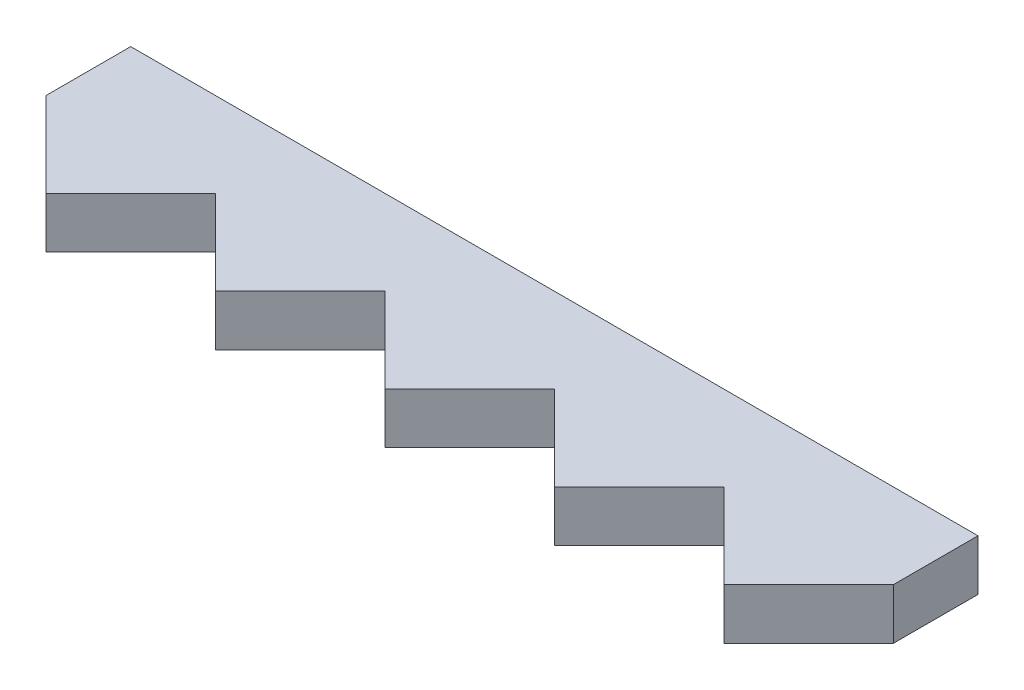
from build123d import *

# Parameters (mm, degrees)
BOSS_EXTRUDE1_DEPTH = 3


with BuildPart() as part:
    # Sketch1 → Boss-Extrude1 (new body)
    with BuildSketch(Plane(origin=(0, 3, 0), x_dir=(1, 0, 0), z_dir=(0, 1, 0))):
        Polygon((0, 71.606428038), (0, 66.606428038), (5, 61.606428038), (10, 66.606428038), (15, 61.606428038), (20, 66.606428038), (25, 61.606428038), (30, 66.606428038), (35, 61.606428038), (40, 66.606428038), (45, 61.606428038), (50, 66.606428038), (50, 71.606428038), align=None)
    extrude(amount=BOSS_EXTRUDE1_DEPTH)


solid = part.part
